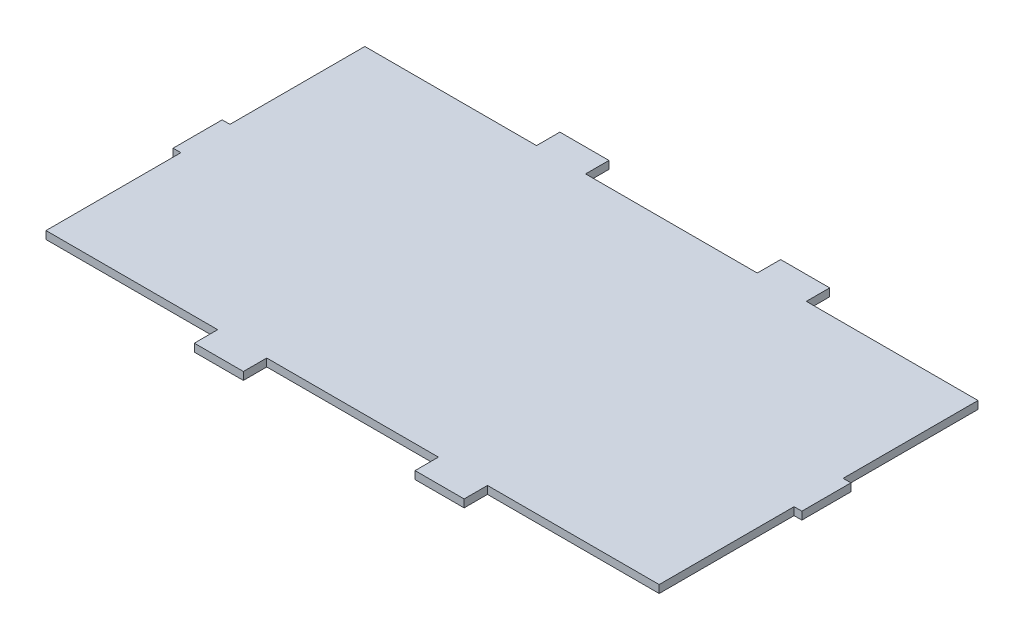
from build123d import *

# Parameters (mm, degrees)
ESQUISSE1_W        = 250
ESQUISSE1_H        = 130
BOSS_EXTRU_1_DEPTH = 3.175
ESQUISSE2_W        = 3.175
ESQUISSE2_H        = 20
ESQUISSE2_W_2      = 20
ESQUISSE2_H_2      = 9.525
BOSS_EXTRU_2_DEPTH = 3.175


with BuildPart() as part:
    # Esquisse1 → Boss.-Extru.1 (new body)
    with BuildSketch(Plane(origin=(0, 0, 0), x_dir=(1, 0, 0), z_dir=(0, 1, 0))):
        with Locations((125, 65)):
            Rectangle(ESQUISSE1_W, ESQUISSE1_H)
    extrude(amount=BOSS_EXTRU_1_DEPTH)

    # Esquisse2 → Boss.-Extru.2 (add)
    with BuildSketch(Plane(origin=(0, 3.175, 0), x_dir=(1, 0, 0), z_dir=(0, 1, 0))):
        with Locations((-1.5875, 65)):
            Rectangle(ESQUISSE2_W, ESQUISSE2_H)
        with Locations((251.5875, 65)):
            Rectangle(ESQUISSE2_W, ESQUISSE2_H)
        with Locations((80, 134.7625)):
            Rectangle(ESQUISSE2_W_2, ESQUISSE2_H_2)
        with Locations((170, 134.7625)):
            Rectangle(ESQUISSE2_W_2, ESQUISSE2_H_2)
        with Locations((170, -4.7625)):
            Rectangle(ESQUISSE2_W_2, ESQUISSE2_H_2)
        with Locations((80, -4.7625)):
            Rectangle(ESQUISSE2_W_2, ESQUISSE2_H_2)
    extrude(amount=-BOSS_EXTRU_2_DEPTH)


solid = part.part
